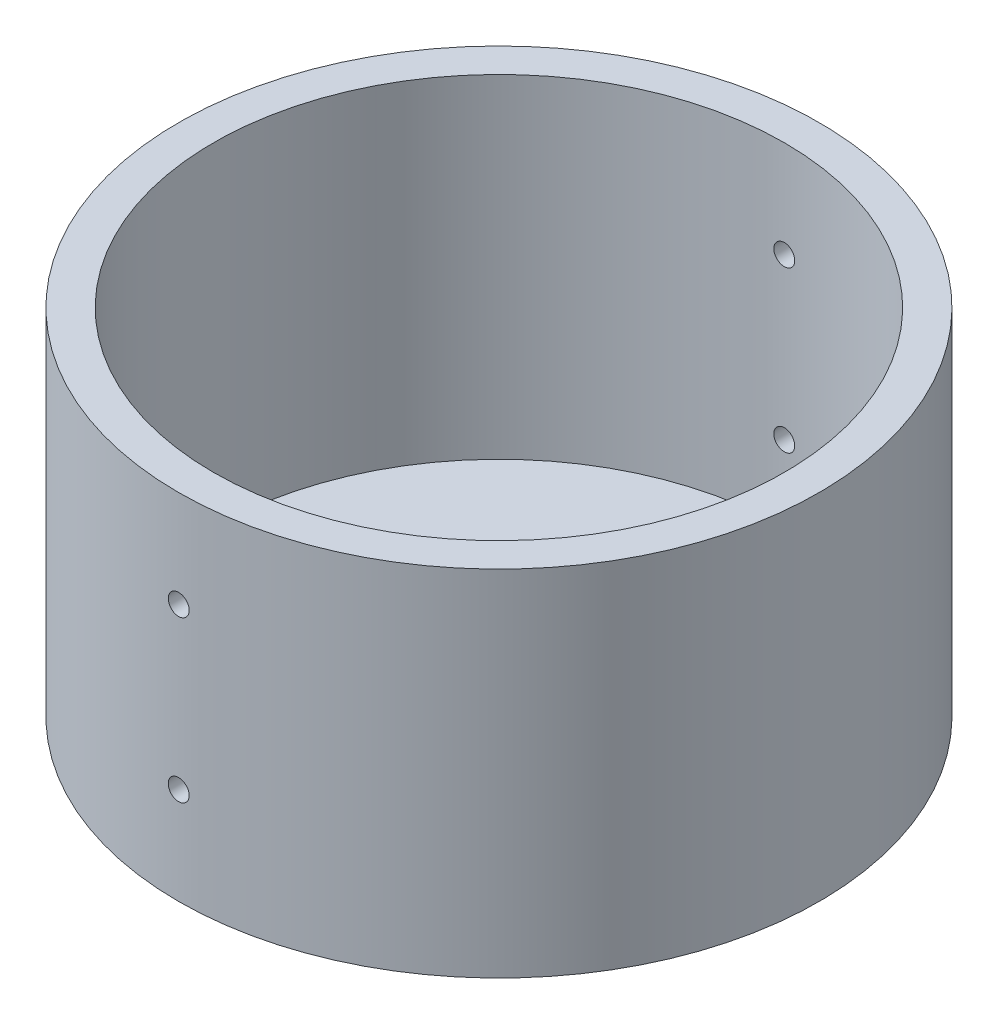
from build123d import *

# Parameters (mm, degrees)
SKETCH1_R               = 45.95
BOSS_EXTRUDE1_DEPTH     = 3
SKETCH2_R               = 45.95
SKETCH2_R_2             = 40.95
BOSS_EXTRUDE2_DEPTH     = 22.4
SKETCH11_R              = 1.5
CUT_EXTRUDE1_DEPTH      = 46.95
CUT_EXTRUDE1_DEPTH_BACK = 46.95
SKETCH12_R              = 45.95
SKETCH12_R_2            = 40.95
BOSS_EXTRUDE3_DEPTH     = 25.4
SKETCH14_R              = 1.5
CUT_EXTRUDE2_DEPTH      = 46.95000011
CUT_EXTRUDE2_DEPTH_BACK = 46.95000011
SKETCH17_R              = 1.5
CUT_EXTRUDE4_DEPTH      = 10
SKETCH15_R              = 4
CUT_EXTRUDE6_DEPTH      = 10


with BuildPart() as part:
    # Sketch1 → Boss-Extrude1 (new body)
    with BuildSketch(Plane(origin=(0, 0, 0), x_dir=(1, 0, 0), z_dir=(0, 1, 0))):
        Circle(SKETCH1_R)
    extrude(amount=BOSS_EXTRUDE1_DEPTH)

    # Sketch2 → Boss-Extrude2 (add)
    with BuildSketch(Plane(origin=(0, 3, 0), x_dir=(1, 0, 0), z_dir=(0, 1, 0))):
        Circle(SKETCH2_R)
        Circle(SKETCH2_R_2, mode=Mode.SUBTRACT)
    extrude(amount=BOSS_EXTRUDE2_DEPTH)

    # Sketch11 → Cut-Extrude1 (cut, two sides)
    with BuildSketch(Plane.XY) as cut_extrude1_sk:
        with Locations((0, 13.9)):
            Circle(SKETCH11_R)
        with Locations((0, -13.9)):
            Circle(SKETCH11_R)
    extrude(amount=CUT_EXTRUDE1_DEPTH, mode=Mode.SUBTRACT)
    extrude(cut_extrude1_sk.sketch, amount=-CUT_EXTRUDE1_DEPTH_BACK, mode=Mode.SUBTRACT)

    # Sketch12 → Boss-Extrude3 (add)
    with BuildSketch(Plane(origin=(0, 25.4, 0), x_dir=(1, 0, 0), z_dir=(0, 1, 0))):
        Circle(SKETCH12_R)
        Circle(SKETCH12_R_2, mode=Mode.SUBTRACT)
    extrude(amount=BOSS_EXTRUDE3_DEPTH)

    # Sketch14 → Cut-Extrude2 (cut, two sides)
    with BuildSketch(Plane.XY) as cut_extrude2_sk:
        with Locations((0, 36.9)):
            Circle(SKETCH14_R)
    extrude(amount=CUT_EXTRUDE2_DEPTH, mode=Mode.SUBTRACT)
    extrude(cut_extrude2_sk.sketch, amount=-CUT_EXTRUDE2_DEPTH_BACK, mode=Mode.SUBTRACT)

    # Sketch17 → Cut-Extrude4 (cut)
    with BuildSketch(Plane(origin=(0, 3, 0), x_dir=(1, 0, 0), z_dir=(0, 1, 0))):
        with Locations((0, 9.5)):
            Circle(SKETCH17_R)
        with Locations((8.227241336, 4.75)):
            Circle(SKETCH17_R)
        with Locations((8.227241336, -4.75)):
            Circle(SKETCH17_R)
        with Locations((0, -9.5)):
            Circle(SKETCH17_R)
        with Locations((-8.227241336, -4.75)):
            Circle(SKETCH17_R)
        with Locations((-8.227241336, 4.75)):
            Circle(SKETCH17_R)
    extrude(amount=-CUT_EXTRUDE4_DEPTH, mode=Mode.SUBTRACT)

    # Sketch15 → Cut-Extrude6 (cut)
    with BuildSketch(Plane(origin=(0, 3, 0), x_dir=(1, 0, 0), z_dir=(0, 1, 0))):
        Circle(SKETCH15_R)
    extrude(amount=-CUT_EXTRUDE6_DEPTH, mode=Mode.SUBTRACT)


solid = part.part
